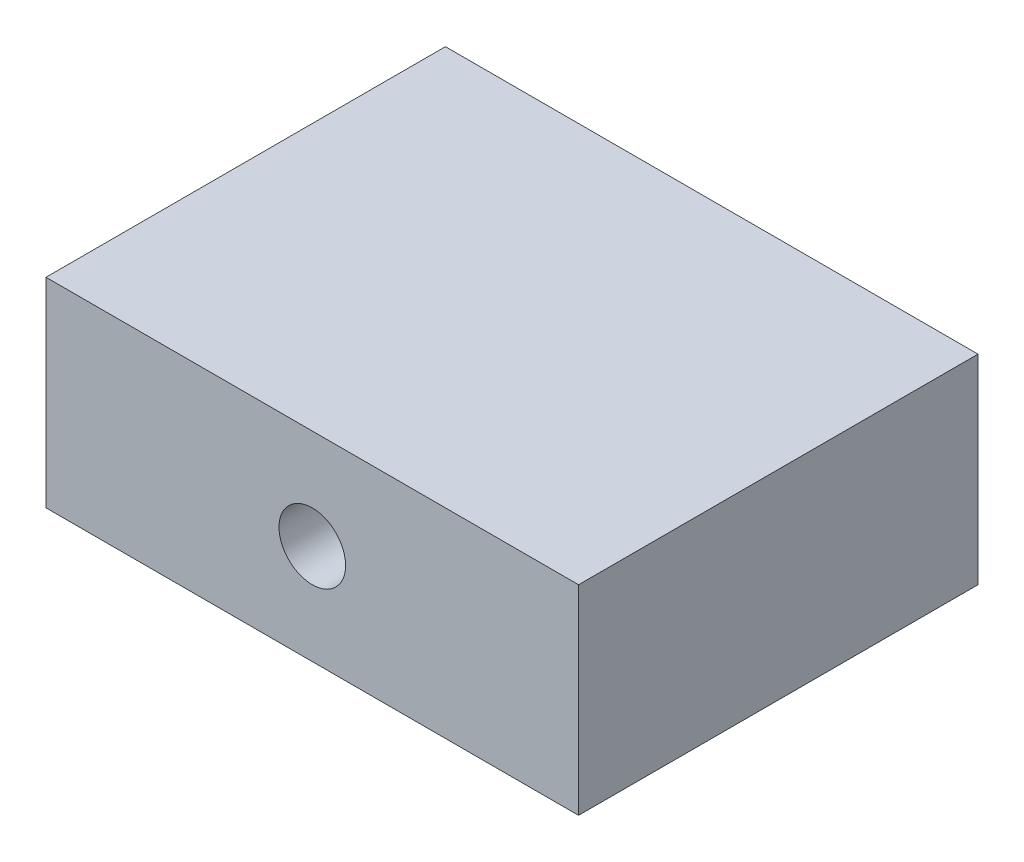
from build123d import *

# Parameters (mm, degrees)
SKETCH_1_W          = 80
SKETCH_1_H          = 60
EXTRUDE_1_DEPTH     = 30
SKETCH_2_R          = 5
CUT_EXTRUDE_1_DEPTH = 61


with BuildPart() as part:
    # 草图1 → 凸台-拉伸1 (new body)
    with BuildSketch(Plane(origin=(0, 0, 0), x_dir=(1, 0, 0), z_dir=(0, 1, 0))):
        Rectangle(SKETCH_1_W, SKETCH_1_H)
    extrude(amount=EXTRUDE_1_DEPTH)

    # 草图2 → 切除-拉伸1 (cut, through all)
    with BuildSketch(Plane.XY.offset(30)):
        with Locations((0, 15)):
            Circle(SKETCH_2_R)
    extrude(amount=-CUT_EXTRUDE_1_DEPTH, mode=Mode.SUBTRACT)


solid = part.part
